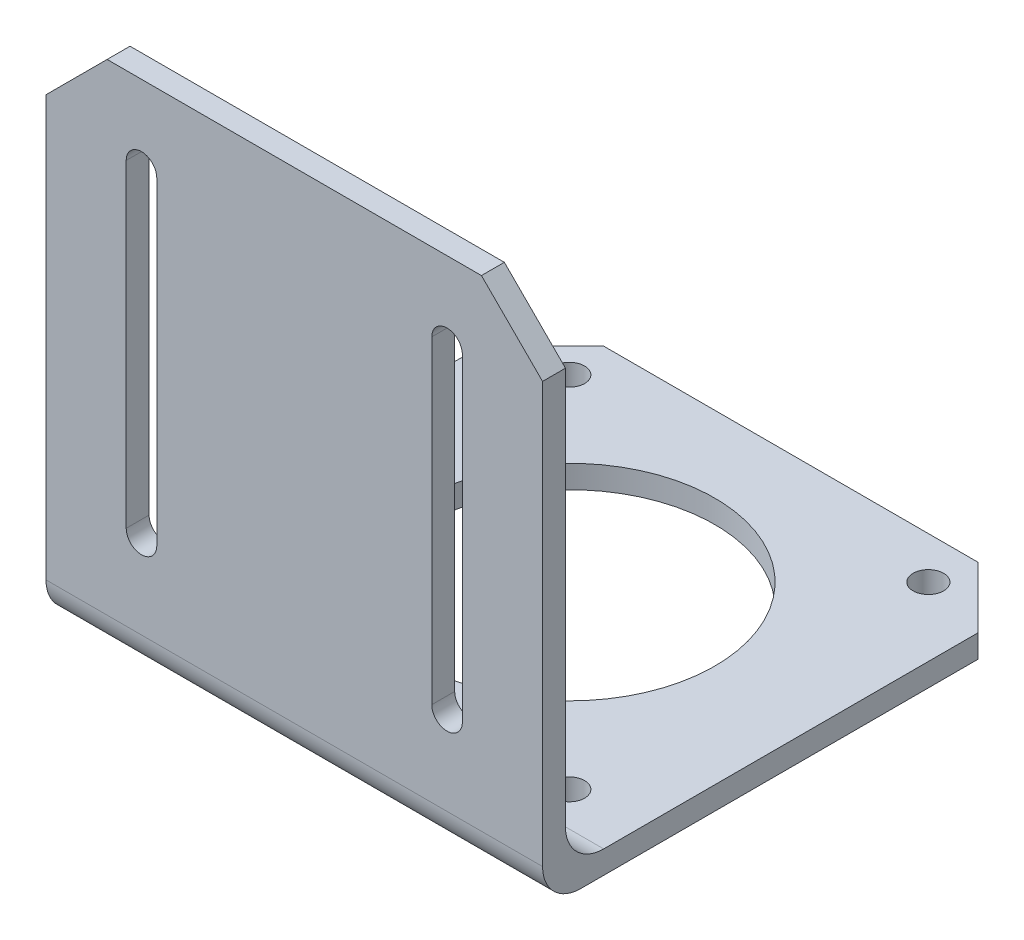
from build123d import *

# Parameters (mm, degrees)
SKETCH_2_W          = 65
SKETCH_2_H          = 65
SKETCH_2_R          = 19.05
SKETCH_2_R_2        = 2
EXTRUDE_2_DEPTH     = 3
CHAMFER_2_SIZE      = 8
SKETCH_3_W          = 65
SKETCH_3_H          = 3
EXTRUDE_3_DEPTH     = 65
FILLET_1_R          = 5
CHAMFER_3_SIZE      = 8
CUT_EXTRUDE_1_DEPTH = 65


with BuildPart() as part:
    # 草圖2 → 填料-伸長2 (new body)
    with BuildSketch(Plane(origin=(0, 0, 0), x_dir=(1, 0, 0), z_dir=(0, 1, 0))):
        Rectangle(SKETCH_2_W, SKETCH_2_H)
        with Locations((0, 3.5)):
            Circle(SKETCH_2_R, mode=Mode.SUBTRACT)
        with Locations((-23.5, 27)):
            Circle(SKETCH_2_R_2, mode=Mode.SUBTRACT)
        with Locations((-23.5, -20)):
            Circle(SKETCH_2_R_2, mode=Mode.SUBTRACT)
        with Locations((23.5, -20)):
            Circle(SKETCH_2_R_2, mode=Mode.SUBTRACT)
        with Locations((23.5, 27)):
            Circle(SKETCH_2_R_2, mode=Mode.SUBTRACT)
    extrude(amount=EXTRUDE_2_DEPTH)

    # 導角2
    chamfer_2_edges = [part.edges().sort_by_distance(p)[0] for p in [
        (-32.5, 1.5, -32.5),
        (32.5, 1.5, -32.5),
    ]]
    chamfer(chamfer_2_edges, length=CHAMFER_2_SIZE)

    # 草圖3 → 填料-伸長3 (add)
    with BuildSketch(Plane(origin=(0, 3, 0), x_dir=(1, 0, 0), z_dir=(0, 1, 0))):
        with Locations((0, -31)):
            Rectangle(SKETCH_3_W, SKETCH_3_H)
    extrude(amount=EXTRUDE_3_DEPTH)

    # 圓角1
    fillet_1_edges = [part.edges().sort_by_distance(p)[0] for p in [
        (0, 0, 32.5),
        (0, 3, 29.5),
    ]]
    fillet(fillet_1_edges, radius=FILLET_1_R)

    # 導角3
    chamfer_3_edges = [part.edges().sort_by_distance(p)[0] for p in [
        (-32.5, 68, 31),
        (32.5, 68, 31),
    ]]
    chamfer(chamfer_3_edges, length=CHAMFER_3_SIZE)

    # 草圖4 → 除料-伸長1 (cut)
    with BuildSketch(Plane(origin=(0, 0, 29.5), x_dir=(-1, 0, 0), z_dir=(0, 0, -1))):
        with BuildLine():
            Line((-18, 57.8), (-18, 16.1))
            ThreePointArc((-18, 16.1), (-20, 14.1), (-22, 16.1))
            Line((-22, 16.1), (-22, 57.8))
            ThreePointArc((-22, 57.8), (-20, 59.8), (-18, 57.8))
        make_face()
        with BuildLine():
            Line((18, 57.8), (18, 16.1))
            ThreePointArc((18, 16.1), (20, 14.1), (22, 16.1))
            Line((22, 16.1), (22, 57.8))
            ThreePointArc((22, 57.8), (20, 59.8), (18, 57.8))
        make_face()
    extrude(amount=-CUT_EXTRUDE_1_DEPTH, mode=Mode.SUBTRACT)


solid = part.part
